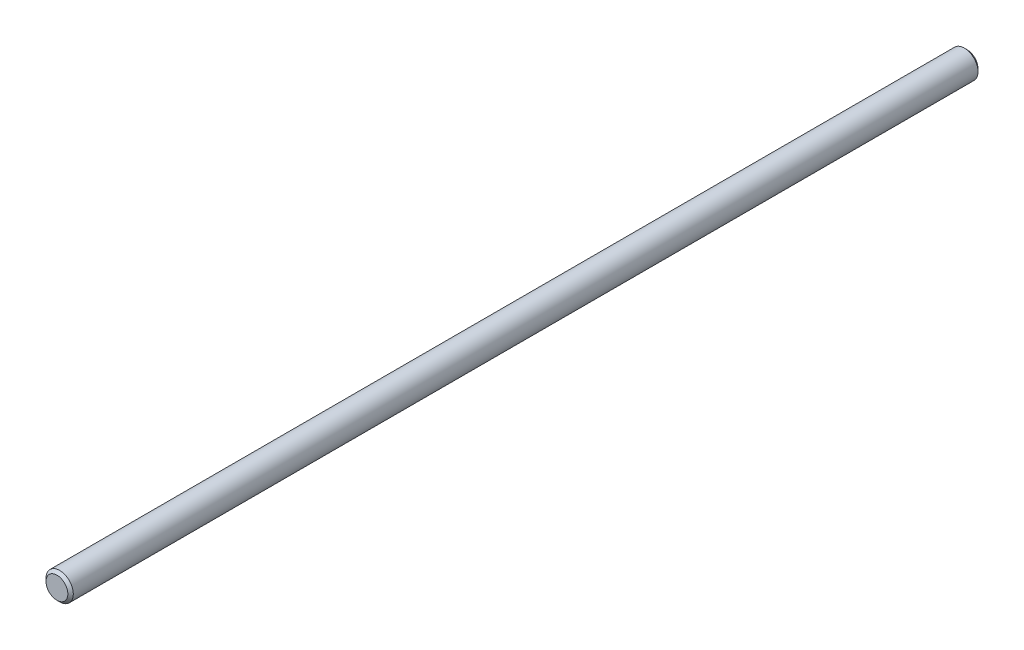
from build123d import *

# Parameters (mm, degrees)
SKETCH1_R      = 6
EXTRUDE1_DEPTH = 200
CHAMFER1_SIZE  = 1.2


with BuildPart() as part:
    # Sketch1 → Extrude1 (new body, symmetric)
    with BuildSketch(Plane.XY):
        Circle(SKETCH1_R)
    extrude(amount=EXTRUDE1_DEPTH, both=True)

    # Chamfer1
    chamfer1_edges = [part.edges().sort_by_distance(p)[0] for p in [
        (-6, 0, -200),
        (-6, 0, 200),
    ]]
    chamfer(chamfer1_edges, length=CHAMFER1_SIZE)


solid = part.part
